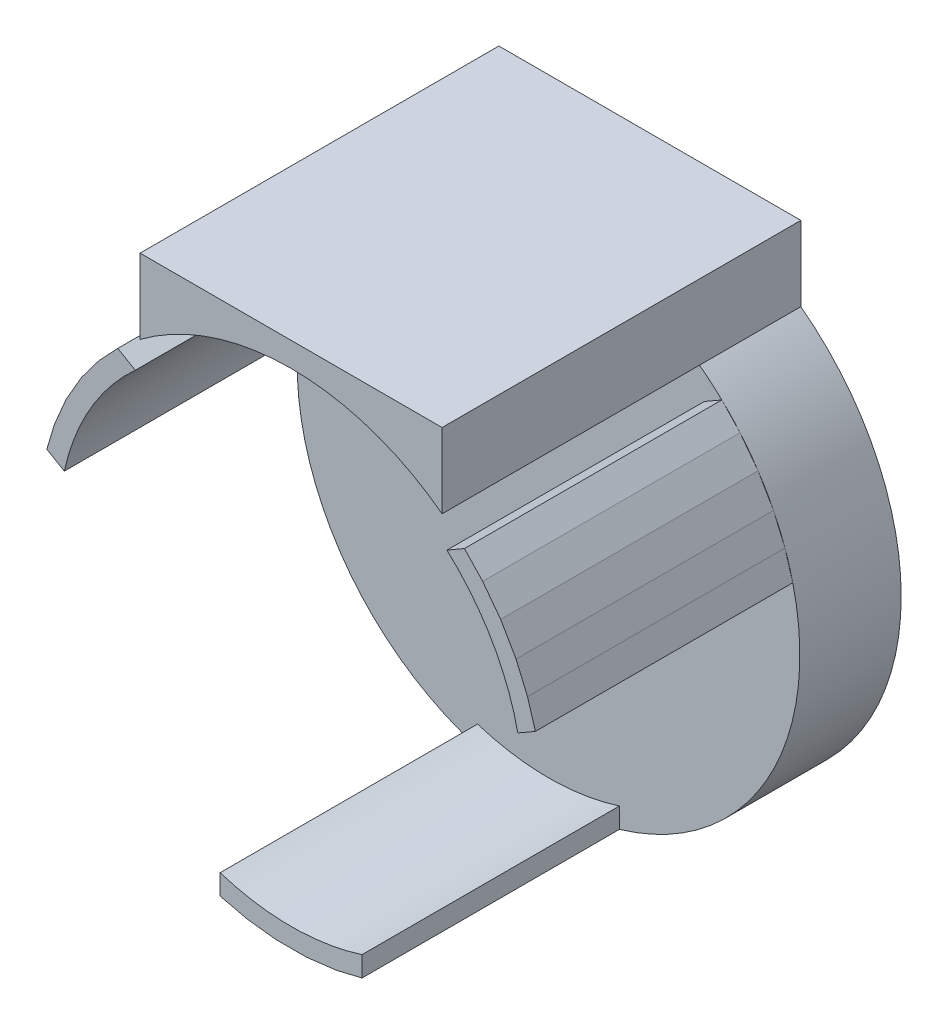
from build123d import *

# Parameters (mm, degrees)
SKETCH2_W              = 26.816018719
SKETCH2_H              = 28.301670726
SQUARE_EXTRUDE_DEPTH   = 5
ACTUAL_SHAPE_CUT_DEPTH = 5
SKETCH3_W              = 14.9
SKETCH3_H              = 3.687507881
STOPPERS_EXTRUDE_DEPTH = 12.7
CURVE_CUT_DEPTH        = 12.7


with BuildPart() as part:
    # Sketch2 → Square extrude (new body)
    with BuildSketch(Plane.XY):
        with Locations((0.074282601, 0.767135851)):
            Rectangle(SKETCH2_W, SKETCH2_H)
    extrude(amount=SQUARE_EXTRUDE_DEPTH)

    # Sketch1 → Actual shape cut (cut)
    with BuildSketch(Plane.XY):
        with BuildLine():
            Line((-17.45, 14.04483891), (-17.45, 23.6))
            Line((-17.45, 23.6), (17.45, 23.6))
            Line((17.45, 23.6), (17.45, 14.04483891))
            ThreePointArc((17.45, 14.04483891), (0, -22.4), (-17.45, 14.04483891))
        make_face()
        with BuildLine():
            Line((-7.45, 9.912492119), (-7.45, 13.6))
            Line((-7.45, 13.6), (7.45, 13.6))
            Line((7.45, 13.6), (7.45, 9.912492119))
            ThreePointArc((7.45, 9.912492119), (0, -12.4), (-7.45, 9.912492119))
        make_face(mode=Mode.SUBTRACT)
    extrude(amount=ACTUAL_SHAPE_CUT_DEPTH, mode=Mode.SUBTRACT)

    # Sketch3 → Stoppers extrude (add)
    with BuildSketch(Plane.XY.offset(5)):
        with Locations((0, 11.75624606)):
            Rectangle(SKETCH3_W, SKETCH3_H)
        with BuildLine():
            Line((3.5, -11.895797577), (3.5, -10.895797577))
            ThreePointArc((3.5, -10.895797577), (0, -11.444142818), (-3.5, -10.895797577))
            Line((-3.5, -10.895797577), (-3.5, -11.895797577))
            Line((-3.5, -11.895797577), (-2.187402084, -12.20554268))
            Line((-2.187402084, -12.20554268), (-0.759747946, -12.376703239))
            Line((-0.759747946, -12.376703239), (0.759747946, -12.376703239))
            Line((0.759747946, -12.376703239), (2.226876894, -12.198402326))
            Line((2.226876894, -12.198402326), (3.5, -11.895797577))
        make_face()
        with BuildLine():
            Line((-12.0520629, 2.916809875), (-11.186037496, 2.416809875))
            ThreePointArc((-11.186037496, 2.416809875), (-9.910918405, 5.722071409), (-7.686037496, 8.478987702))
            Line((-7.686037496, 8.478987702), (-8.5520629, 8.978987702))
            Line((-8.5520629, 8.978987702), (-9.476608986, 7.997117113))
            Line((-9.476608986, 7.997117113), (-10.338665447, 6.846312641))
            Line((-10.338665447, 6.846312641), (-11.098413393, 5.530390597))
            Line((-11.098413393, 5.530390597), (-11.677564746, 4.170669202))
            Line((-11.677564746, 4.170669202), (-12.0520629, 2.916809875))
        make_face()
        with BuildLine():
            Line((8.5520629, 8.978987702), (7.686037496, 8.478987702))
            ThreePointArc((7.686037496, 8.478987702), (9.910918405, 5.722071409), (11.186037496, 2.416809875))
            Line((11.186037496, 2.416809875), (12.0520629, 2.916809875))
            Line((12.0520629, 2.916809875), (11.66401107, 4.208425567))
            Line((11.66401107, 4.208425567), (11.098413393, 5.530390597))
            Line((11.098413393, 5.530390597), (10.338665447, 6.846312641))
            Line((10.338665447, 6.846312641), (9.450687853, 8.027733124))
            Line((9.450687853, 8.027733124), (8.5520629, 8.978987702))
        make_face()
    extrude(amount=STOPPERS_EXTRUDE_DEPTH)

    # Sketch4 → Curve cut (cut)
    with BuildSketch(Plane.XY.offset(17.7)):
        with BuildLine():
            Line((-7.45, 9.912492119), (7.45, 9.912492119))
            ThreePointArc((7.45, 9.912492119), (0, 12.4), (-7.45, 9.912492119))
        make_face()
    extrude(amount=-CURVE_CUT_DEPTH, mode=Mode.SUBTRACT)


solid = part.part
